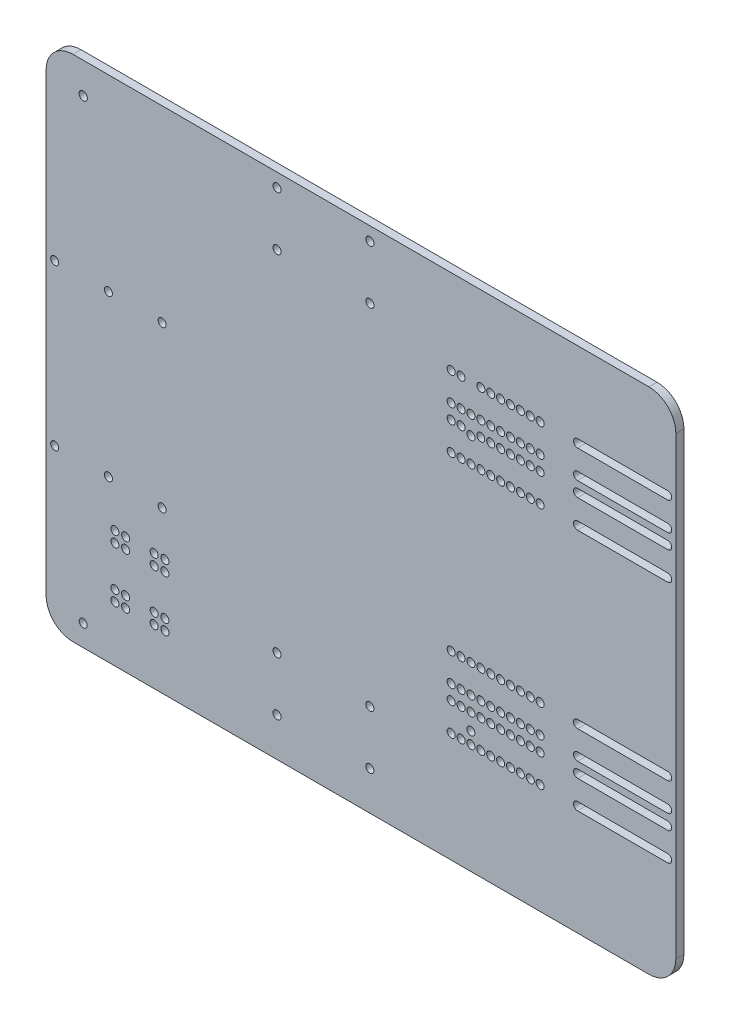
from build123d import *

# Parameters (mm, degrees)
SKETCH_1_W          = 234.458440399
SKETCH_1_H          = 189.431439409
SKETCH_1_R          = 1.5
EXTRUDE_1_DEPTH     = 3
FILLET_1_R          = 10
SKETCH_2_R          = 1.5
CUT_EXTRUDE_1_DEPTH = 153.126694016
SKETCH_4_R          = 1.570409253
SKETCH_4_R_2        = 1.5
CUT_EXTRUDE_2_DEPTH = 153.126694016
SKETCH_6_R          = 1.5
CUT_EXTRUDE_3_DEPTH = 153.126694016


with BuildPart() as part:
    # 草图1 → 凸台-拉伸1 (new body)
    with BuildSketch(Plane.XY):
        with Locations((1.643745524, -0.167097773)):
            Rectangle(SKETCH_1_W, SKETCH_1_H)
        with Locations((-72.385738579, 24.638125192)):
            Circle(SKETCH_1_R, mode=Mode.SUBTRACT)
        with Locations((-72.385738579, -35.081993259)):
            Circle(SKETCH_1_R, mode=Mode.SUBTRACT)
    extrude(amount=EXTRUDE_1_DEPTH)

    # 圆角1
    fillet_1_edges = [part.edges().sort_by_distance(p)[0] for p in [
        (118.872965723, 94.548621932, 1.5),
        (-115.585474676, 94.548621932, 1.5),
        (-115.585474676, -94.882817477, 1.5),
        (118.872965723, -94.882817477, 1.5),
    ]]
    fillet(fillet_1_edges, radius=FILLET_1_R)

    # 草图2 → 切除-拉伸1 (cut, through all)
    with BuildSketch(Plane.XY.offset(3)):
        with Locations((-71.362965723, -51.222817477)):
            Circle(SKETCH_2_R)
        with Locations((-71.362965723, -70.222817477)):
            Circle(SKETCH_2_R)
        with Locations((-85.982965723, -51.222817477)):
            Circle(SKETCH_2_R)
        with Locations((-85.982965723, -70.222817477)):
            Circle(SKETCH_2_R)
        with Locations((-89.982965723, -51.222817477)):
            Circle(SKETCH_2_R)
        with Locations((-75.362965723, -51.222817477)):
            Circle(SKETCH_2_R)
        with Locations((-89.982965723, -70.222817477)):
            Circle(SKETCH_2_R)
        with Locations((-75.362965723, -70.222817477)):
            Circle(SKETCH_2_R)
        with Locations((-85.982965723, -55.222817477)):
            Circle(SKETCH_2_R)
        with Locations((-71.362965723, -55.222817477)):
            Circle(SKETCH_2_R)
        with Locations((-85.982965723, -74.222817477)):
            Circle(SKETCH_2_R)
        with Locations((-71.362965723, -74.222817477)):
            Circle(SKETCH_2_R)
        with Locations((-89.982965723, -55.222817477)):
            Circle(SKETCH_2_R)
        with Locations((-75.362965723, -55.222817477)):
            Circle(SKETCH_2_R)
        with Locations((-89.982965723, -74.222817477)):
            Circle(SKETCH_2_R)
        with Locations((-75.362965723, -74.222817477)):
            Circle(SKETCH_2_R)
    extrude(amount=-CUT_EXTRUDE_1_DEPTH, mode=Mode.SUBTRACT)

    # 草图4 → 切除-拉伸2 (cut, through all)
    with BuildSketch(Plane.XY.offset(3)):
        with Locations((-101.767034277, 83.048621932)):
            Circle(SKETCH_4_R)
        with Locations((-101.767034277, -86.951378068)):
            Circle(SKETCH_4_R_2)
        with Locations((42.581866104, 45.669379407)):
            Circle(SKETCH_4_R_2)
        with Locations((42.581866104, -49.572135543)):
            Circle(SKETCH_4_R_2)
        with Locations((-112.385738579, 24.638125192)):
            Circle(SKETCH_4_R_2)
        with Locations((-112.385738579, -35.081993259)):
            Circle(SKETCH_4_R_2)
        with Locations((-92.385738579, 24.638125192)):
            Circle(SKETCH_4_R_2)
        with Locations((-92.385738579, -35.081993259)):
            Circle(SKETCH_4_R_2)
    extrude(amount=-CUT_EXTRUDE_2_DEPTH, mode=Mode.SUBTRACT)

    # 草图6 → 切除-拉伸3 (cut, through all)
    with BuildSketch(Plane.XY.offset(3)):
        with Locations((46.274853951, 63.048621932)):
            Circle(SKETCH_6_R)
        with Locations((46.274853951, -53.951378068)):
            Circle(SKETCH_6_R)
        with Locations((46.274853951, -43.451378068)):
            Circle(SKETCH_6_R)
        with Locations((46.274853951, -37.951378068)):
            Circle(SKETCH_6_R)
        with Locations((46.274853951, 36.548621932)):
            Circle(SKETCH_6_R)
        with Locations((46.274853951, -27.451378068)):
            Circle(SKETCH_6_R)
        with Locations((46.274853951, 52.548621932)):
            Circle(SKETCH_6_R)
        with BuildLine():
            ThreePointArc((47.676419889, 47.583049589), (44.774853951, 47.048621932), (47.676419889, 46.514194275))
            Line((47.676419889, 46.514194275), (47.676419889, 47.583049589))
        make_face()
        with BuildLine():
            Line((82.273571171, 51.048621932), (115.85404507, 51.048621932))
            ThreePointArc((115.85404507, 51.048621932), (117.35404507, 52.548621932), (115.85404507, 54.048621932))
            Line((115.85404507, 54.048621932), (82.273571171, 54.048621932))
            ThreePointArc((82.273571171, 54.048621932), (80.773571171, 52.548621932), (82.273571171, 51.048621932))
        make_face()
        with BuildLine():
            Line((115.85404507, 38.048621932), (82.273571171, 38.048621932))
            ThreePointArc((82.273571171, 38.048621932), (80.773571171, 36.548621932), (82.273571171, 35.048621932))
            Line((82.273571171, 35.048621932), (115.85404507, 35.048621932))
            ThreePointArc((115.85404507, 35.048621932), (117.35404507, 36.548621932), (115.85404507, 38.048621932))
        make_face()
        with BuildLine():
            Line((82.273571171, 45.548621932), (115.85404507, 45.548621932))
            ThreePointArc((115.85404507, 45.548621932), (117.35404507, 47.048621932), (115.85404507, 48.548621932))
            Line((115.85404507, 48.548621932), (82.273571171, 48.548621932))
            ThreePointArc((82.273571171, 48.548621932), (80.773571171, 47.048621932), (82.273571171, 45.548621932))
        make_face()
        with BuildLine():
            Line((82.273571171, 61.548621932), (115.85404507, 61.548621932))
            ThreePointArc((115.85404507, 61.548621932), (117.35404507, 63.048621932), (115.85404507, 64.548621932))
            Line((115.85404507, 64.548621932), (82.273571171, 64.548621932))
            ThreePointArc((82.273571171, 64.548621932), (80.773571171, 63.048621932), (82.273571171, 61.548621932))
        make_face()
        with BuildLine():
            Line((115.85404507, -25.951378068), (82.273571171, -25.951378068))
            ThreePointArc((82.273571171, -25.951378068), (80.773571171, -27.451378068), (82.273571171, -28.951378068))
            Line((82.273571171, -28.951378068), (115.85404507, -28.951378068))
            ThreePointArc((115.85404507, -28.951378068), (117.35404507, -27.451378068), (115.85404507, -25.951378068))
        make_face()
        with BuildLine():
            Line((115.85404507, -36.451378068), (82.273571171, -36.451378068))
            ThreePointArc((82.273571171, -36.451378068), (80.773571171, -37.951378068), (82.273571171, -39.451378068))
            Line((82.273571171, -39.451378068), (115.85404507, -39.451378068))
            ThreePointArc((115.85404507, -39.451378068), (117.35404507, -37.951378068), (115.85404507, -36.451378068))
        make_face()
        with BuildLine():
            Line((115.85404507, -41.951378068), (82.273571171, -41.951378068))
            ThreePointArc((82.273571171, -41.951378068), (80.773571171, -43.451378068), (82.273571171, -44.951378068))
            Line((82.273571171, -44.951378068), (115.85404507, -44.951378068))
            ThreePointArc((115.85404507, -44.951378068), (117.35404507, -43.451378068), (115.85404507, -41.951378068))
        make_face()
        with BuildLine():
            Line((115.85404507, -52.451378068), (82.273571171, -52.451378068))
            ThreePointArc((82.273571171, -52.451378068), (80.773571171, -53.951378068), (82.273571171, -55.451378068))
            Line((82.273571171, -55.451378068), (115.85404507, -55.451378068))
            ThreePointArc((115.85404507, -55.451378068), (117.35404507, -53.951378068), (115.85404507, -52.451378068))
        make_face()
        with Locations((-29.609621544, 89.548621932)):
            Circle(SKETCH_6_R)
        with Locations((4.962461322, -60.451378068)):
            Circle(SKETCH_6_R)
        with Locations((-29.609621544, -80.451378068)):
            Circle(SKETCH_6_R)
        with Locations((4.962461322, -80.451378068)):
            Circle(SKETCH_6_R)
        with Locations((4.962461322, 89.548621932)):
            Circle(SKETCH_6_R)
        with Locations((-29.609621544, 69.548621932)):
            Circle(SKETCH_6_R)
        with Locations((-29.609621544, -60.451378068)):
            Circle(SKETCH_6_R)
        with Locations((49.954853951, -27.451378068)):
            Circle(SKETCH_6_R)
        with Locations((49.954853951, -43.451378068)):
            Circle(SKETCH_6_R)
        with Locations((53.634853951, -27.451378068)):
            Circle(SKETCH_6_R)
        with Locations((53.634853951, -43.451378068)):
            Circle(SKETCH_6_R)
        with Locations((57.314853951, -27.451378068)):
            Circle(SKETCH_6_R)
        with Locations((57.314853951, -43.451378068)):
            Circle(SKETCH_6_R)
        with Locations((60.994853951, -27.451378068)):
            Circle(SKETCH_6_R)
        with Locations((60.994853951, -43.451378068)):
            Circle(SKETCH_6_R)
        with Locations((64.674853951, -27.451378068)):
            Circle(SKETCH_6_R)
        with Locations((64.674853951, -43.451378068)):
            Circle(SKETCH_6_R)
        with Locations((68.354853951, -27.451378068)):
            Circle(SKETCH_6_R)
        with Locations((68.354853951, -43.451378068)):
            Circle(SKETCH_6_R)
        with Locations((68.354853951, 52.548621932)):
            Circle(SKETCH_6_R)
        with Locations((68.354853951, 36.548621932)):
            Circle(SKETCH_6_R)
        with Locations((64.674853951, 52.548621932)):
            Circle(SKETCH_6_R)
        with Locations((64.674853951, 36.548621932)):
            Circle(SKETCH_6_R)
        with Locations((60.994853951, 52.548621932)):
            Circle(SKETCH_6_R)
        with Locations((60.994853951, 36.548621932)):
            Circle(SKETCH_6_R)
        with Locations((57.314853951, 52.548621932)):
            Circle(SKETCH_6_R)
        with Locations((57.314853951, 36.548621932)):
            Circle(SKETCH_6_R)
        with Locations((53.634853951, 52.548621932)):
            Circle(SKETCH_6_R)
        with Locations((53.634853951, 36.548621932)):
            Circle(SKETCH_6_R)
        with Locations((49.954853951, 52.548621932)):
            Circle(SKETCH_6_R)
        with Locations((49.954853951, 36.548621932)):
            Circle(SKETCH_6_R)
        with Locations((68.354853951, 63.048621932)):
            Circle(SKETCH_6_R)
        with Locations((49.954853951, 63.048621932)):
            Circle(SKETCH_6_R)
        with Locations((57.314853951, 63.048621932)):
            Circle(SKETCH_6_R)
        with Locations((64.674853951, 47.048621932)):
            Circle(SKETCH_6_R)
        with Locations((49.954853951, 47.048621932)):
            Circle(SKETCH_6_R)
        with Locations((53.634853951, 63.048621932)):
            Circle(SKETCH_6_R)
        with Locations((60.994853951, 63.048621932)):
            Circle(SKETCH_6_R)
        with Locations((64.674853951, 63.048621932)):
            Circle(SKETCH_6_R)
        with Locations((57.314853951, 47.048621932)):
            Circle(SKETCH_6_R)
        with Locations((53.634853951, 47.048621932)):
            Circle(SKETCH_6_R)
        with Locations((60.994853951, 47.048621932)):
            Circle(SKETCH_6_R)
        with Locations((68.354853951, 47.048621932)):
            Circle(SKETCH_6_R)
        with Locations((49.954853951, -37.951378068)):
            Circle(SKETCH_6_R)
        with Locations((68.354853951, -37.951378068)):
            Circle(SKETCH_6_R)
        with Locations((60.994853951, -37.951378068)):
            Circle(SKETCH_6_R)
        with Locations((53.634853951, -37.951378068)):
            Circle(SKETCH_6_R)
        with Locations((57.314853951, -37.951378068)):
            Circle(SKETCH_6_R)
        with Locations((64.674853951, -37.951378068)):
            Circle(SKETCH_6_R)
        with Locations((49.954853951, -53.951378068)):
            Circle(SKETCH_6_R)
        with Locations((64.674853951, -53.951378068)):
            Circle(SKETCH_6_R)
        with Locations((60.994853951, -53.951378068)):
            Circle(SKETCH_6_R)
        with Locations((53.634853951, -53.951378068)):
            Circle(SKETCH_6_R)
        with Locations((57.314853951, -53.951378068)):
            Circle(SKETCH_6_R)
        with Locations((68.354853951, -53.951378068)):
            Circle(SKETCH_6_R)
        with Locations((4.962461322, 69.548621932)):
            Circle(SKETCH_6_R)
        with Locations((42.594853951, 52.548621932)):
            Circle(SKETCH_6_R)
        with Locations((42.594853951, 36.548621932)):
            Circle(SKETCH_6_R)
        with Locations((42.594853951, -27.451378068)):
            Circle(SKETCH_6_R)
        with Locations((42.594853951, -37.951378068)):
            Circle(SKETCH_6_R)
        with Locations((42.594853951, -43.451378068)):
            Circle(SKETCH_6_R)
        with Locations((42.594853951, -53.951378068)):
            Circle(SKETCH_6_R)
        with Locations((38.914853951, 63.048621932)):
            Circle(SKETCH_6_R)
        with Locations((38.914853951, 52.548621932)):
            Circle(SKETCH_6_R)
        with Locations((38.914853951, 47.048621932)):
            Circle(SKETCH_6_R)
        with Locations((38.914853951, 36.548621932)):
            Circle(SKETCH_6_R)
        with Locations((38.914853951, -27.451378068)):
            Circle(SKETCH_6_R)
        with Locations((38.914853951, -37.951378068)):
            Circle(SKETCH_6_R)
        with Locations((38.914853951, -43.451378068)):
            Circle(SKETCH_6_R)
        with Locations((38.914853951, -53.951378068)):
            Circle(SKETCH_6_R)
        with Locations((35.234853951, 63.048621932)):
            Circle(SKETCH_6_R)
        with Locations((35.234853951, 52.548621932)):
            Circle(SKETCH_6_R)
        with Locations((35.234853951, 47.048621932)):
            Circle(SKETCH_6_R)
        with Locations((35.234853951, 36.548621932)):
            Circle(SKETCH_6_R)
        with Locations((35.234853951, -27.451378068)):
            Circle(SKETCH_6_R)
        with Locations((35.234853951, -37.951378068)):
            Circle(SKETCH_6_R)
        with Locations((35.234853951, -43.451378068)):
            Circle(SKETCH_6_R)
        with Locations((35.234853951, -53.951378068)):
            Circle(SKETCH_6_R)
    extrude(amount=-CUT_EXTRUDE_3_DEPTH, mode=Mode.SUBTRACT)


solid = part.part
